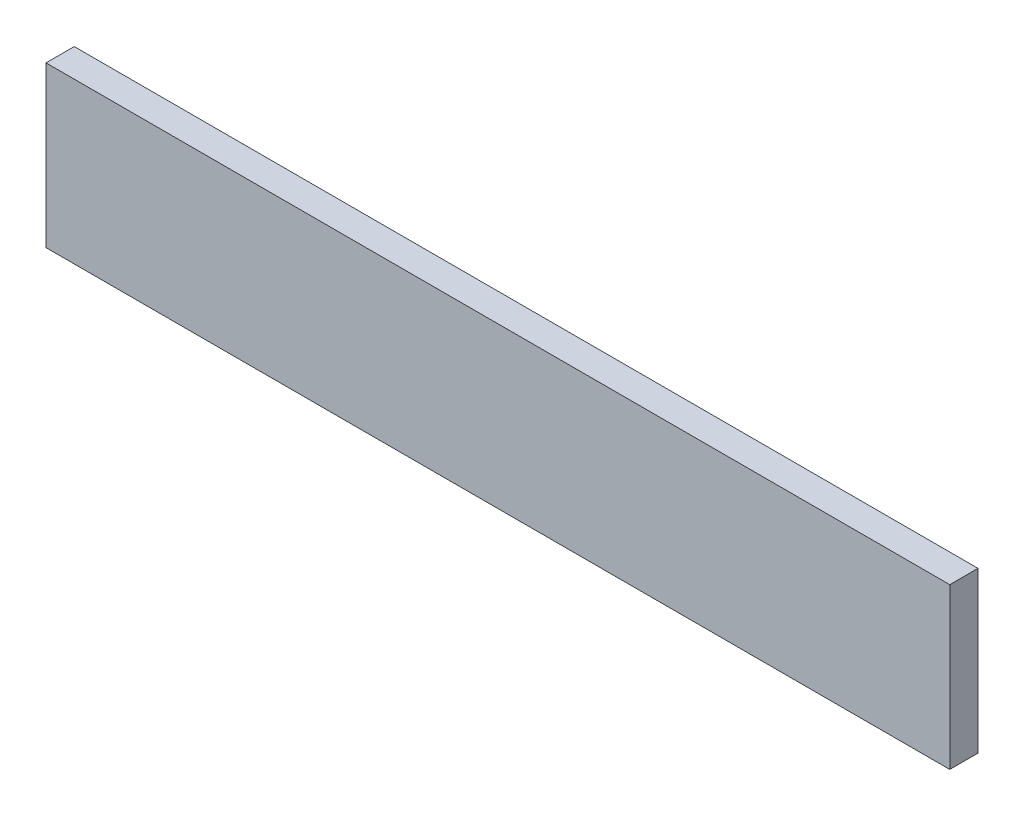
from build123d import *

# Parameters (mm, degrees)
SKETCH1_W           = 609.6
SKETCH1_H           = 107.95
BOSS_EXTRUDE1_DEPTH = 19.05


with BuildPart() as part:
    # Sketch1 → Boss-Extrude1 (new body)
    with BuildSketch(Plane.XY):
        with Locations((304.8, 53.975)):
            Rectangle(SKETCH1_W, SKETCH1_H)
    extrude(amount=BOSS_EXTRUDE1_DEPTH)


solid = part.part
